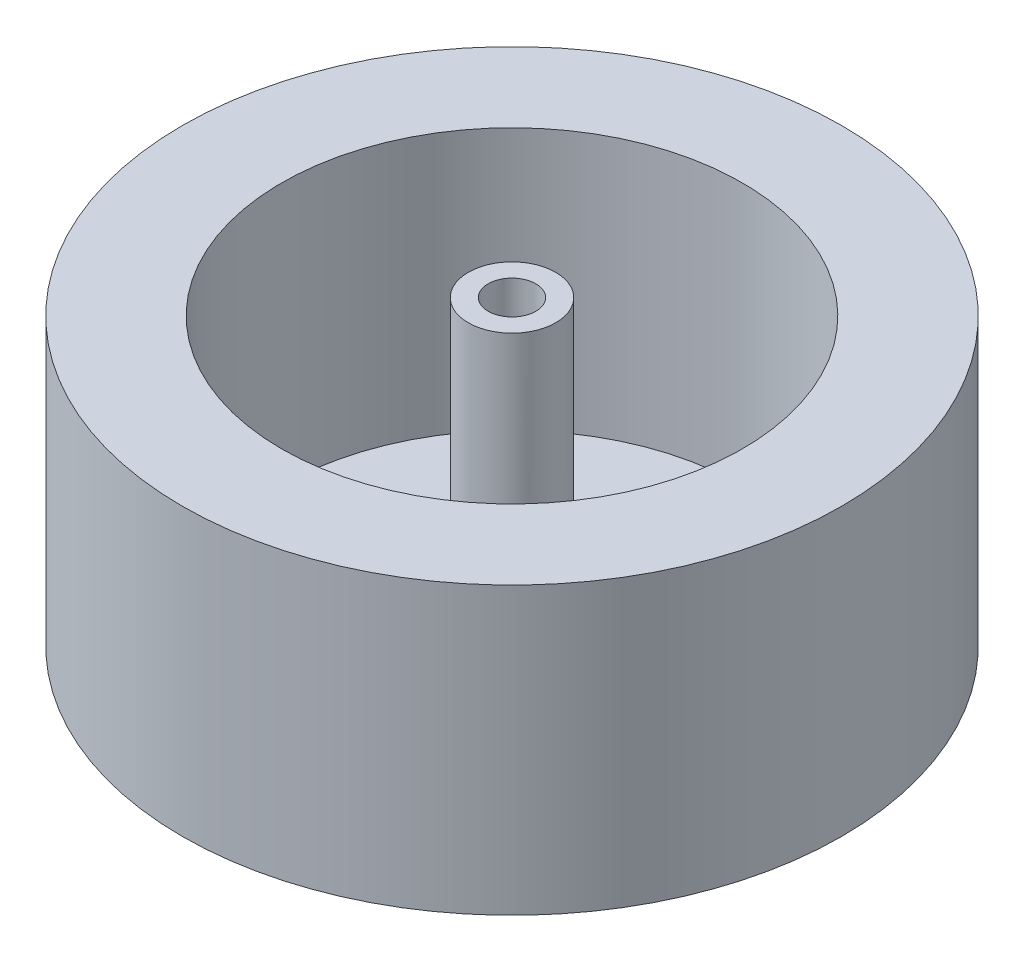
from build123d import *

# Parameters (mm, degrees)
SKETCH_1_R          = 41.5
SKETCH_1_R_2        = 29
EXTRUDE_1_DEPTH     = 33
SKETCH_2_R          = 41.5
EXTRUDE_2_DEPTH     = 3
SKETCH_3_R          = 2
CUT_EXTRUDE_1_DEPTH = 4
SKETCH_4_R          = 5.5
SKETCH_4_R_2        = 3
EXTRUDE_3_DEPTH     = 35


with BuildPart() as part:
    # 草图1 → 凸台-拉伸1 (new body)
    with BuildSketch(Plane(origin=(0, 0, 0), x_dir=(1, 0, 0), z_dir=(0, 1, 0))):
        Circle(SKETCH_1_R)
        Circle(SKETCH_1_R_2, mode=Mode.SUBTRACT)
    extrude(amount=EXTRUDE_1_DEPTH)

    # 草图2 → 凸台-拉伸2 (add)
    with BuildSketch(Plane.XZ):
        Circle(SKETCH_2_R)
    extrude(amount=EXTRUDE_2_DEPTH)

    # 草图3 → 切除-拉伸1 (cut, through all)
    with BuildSketch(Plane(origin=(0, 0, 0), x_dir=(1, 0, 0), z_dir=(0, 1, 0))):
        Circle(SKETCH_3_R)
    extrude(amount=-CUT_EXTRUDE_1_DEPTH, mode=Mode.SUBTRACT)

    # 草图4 → 凸台-拉伸3 (add)
    with BuildSketch(Plane(origin=(0, 0, 0), x_dir=(1, 0, 0), z_dir=(0, 1, 0))):
        Circle(SKETCH_4_R)
        Circle(SKETCH_4_R_2, mode=Mode.SUBTRACT)
    extrude(amount=EXTRUDE_3_DEPTH)


solid = part.part
